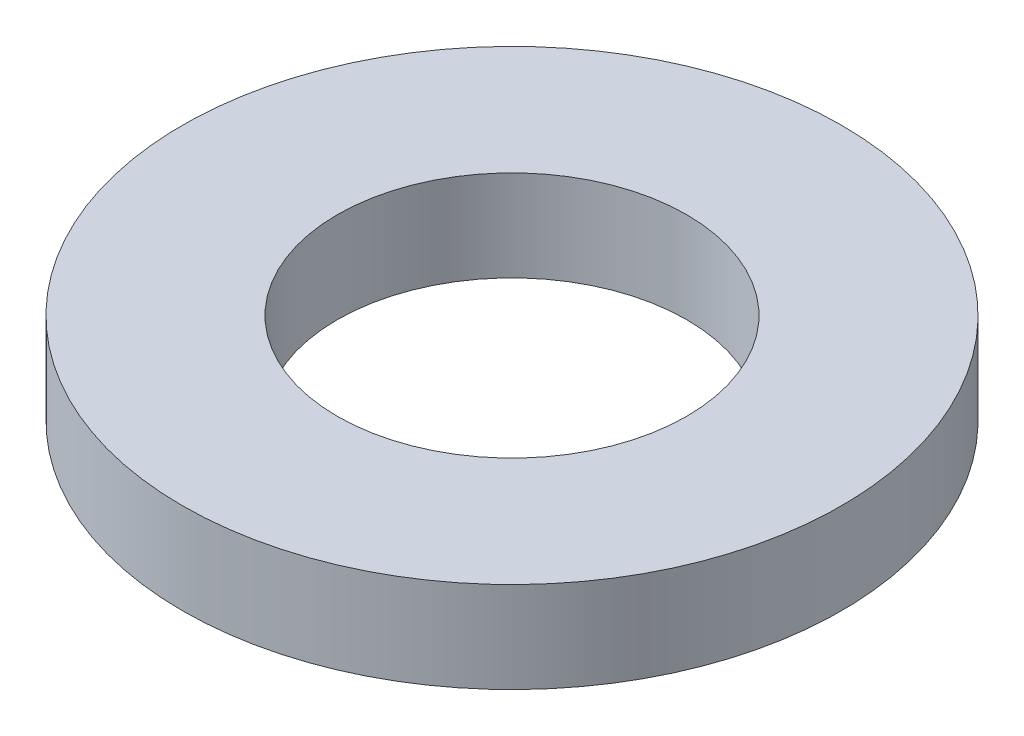
from build123d import *

# Parameters (mm, degrees)
SKETCH1_R           = 6.35
BOSS_EXTRUDE1_DEPTH = 1.7526
SKETCH5_R           = 3.3655
CUT_EXTRUDE1_DEPTH  = 2.7526


with BuildPart() as part:
    # Sketch1 → Boss-Extrude1 (new body)
    with BuildSketch(Plane(origin=(0, 0, 0), x_dir=(1, 0, 0), z_dir=(0, 1, 0))):
        Circle(SKETCH1_R)
    extrude(amount=BOSS_EXTRUDE1_DEPTH)

    # Sketch5 → Cut-Extrude1 (cut, through all)
    with BuildSketch(Plane(origin=(0, 1.7526, 0), x_dir=(-1, 0, 0), z_dir=(0, 1, 0))):
        Circle(SKETCH5_R)
    extrude(amount=-CUT_EXTRUDE1_DEPTH, mode=Mode.SUBTRACT)


solid = part.part
